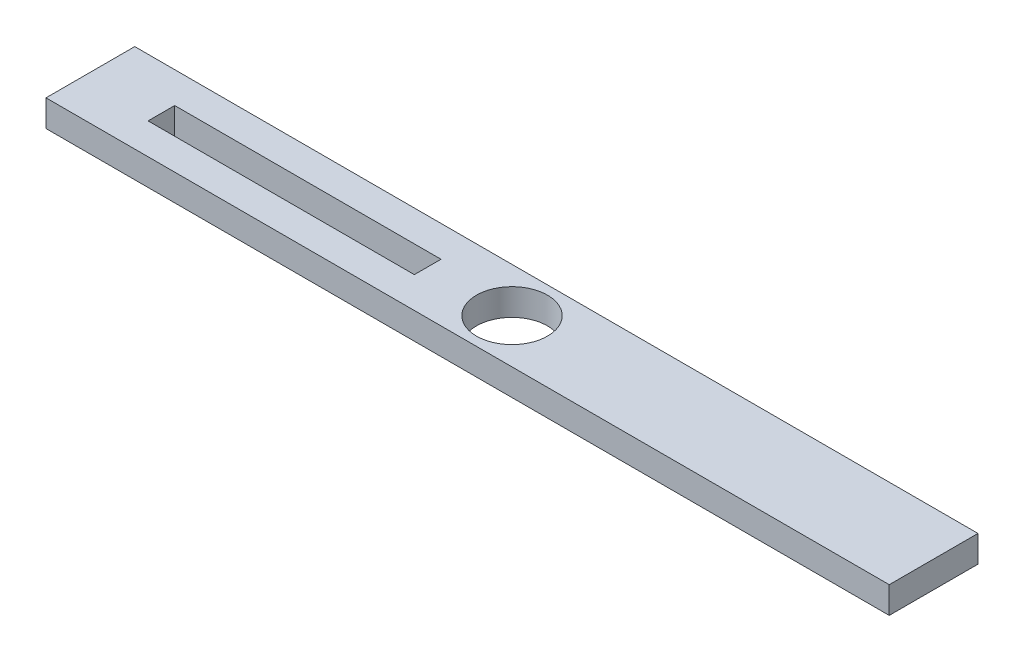
from build123d import *

# Parameters (mm, degrees)
CROQUIS1_W              = 95
CROQUIS1_H              = 10
CROQUIS1_R              = 4
CROQUIS1_W_2            = 30
CROQUIS1_H_2            = 3
SALIENTE_EXTRUIR1_DEPTH = 3


with BuildPart() as part:
    # Croquis1 → Saliente-Extruir1 (new body)
    with BuildSketch(Plane(origin=(0, 0, 0), x_dir=(1, 0, 0), z_dir=(0, 1, 0))):
        Rectangle(CROQUIS1_W, CROQUIS1_H)
        Circle(CROQUIS1_R, mode=Mode.SUBTRACT)
        with Locations((-24.5, 0)):
            Rectangle(CROQUIS1_W_2, CROQUIS1_H_2, mode=Mode.SUBTRACT)
    extrude(amount=SALIENTE_EXTRUIR1_DEPTH)


solid = part.part
